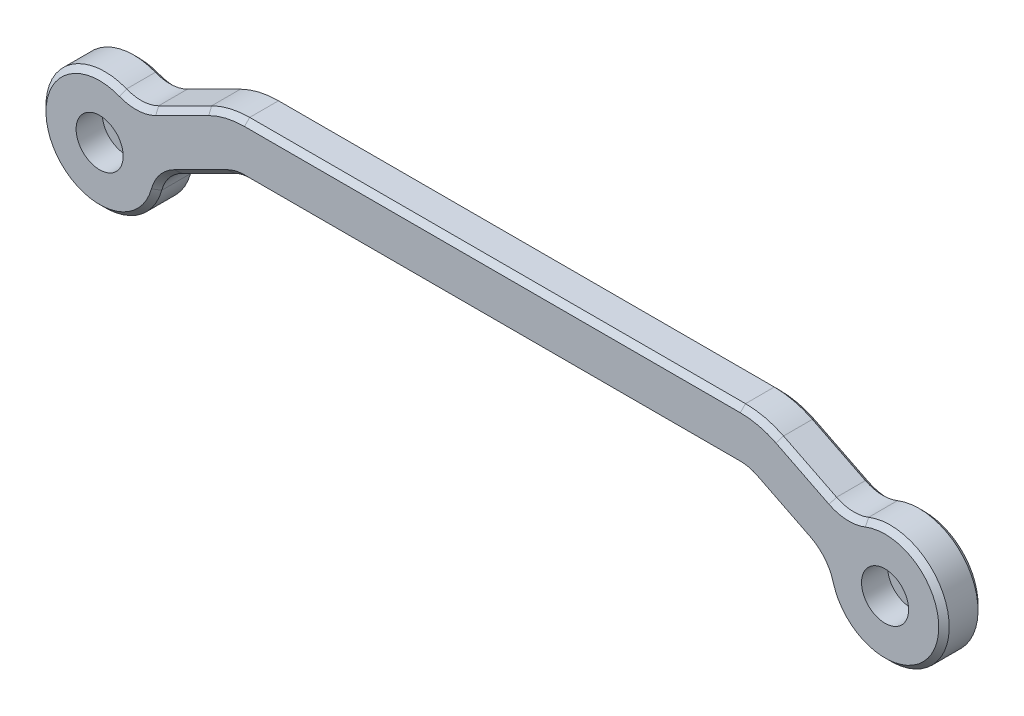
from build123d import *

# Parameters (mm, degrees)
SKETCH1_R           = 2.05
BOSS_EXTRUDE1_DEPTH = 6
SKETCH3_R           = 3.6
CUT_EXTRUDE1_DEPTH  = 4
CHAMFER3_SIZE       = 0.8


with BuildPart() as part:
    # Sketch1 → Boss-Extrude1 (new body)
    with BuildSketch(Plane.XY):
        with BuildLine():
            Line((-51.788854382, 8.577708764), (-43.689164944, 12.627553483))
            ThreePointArc((-43.689164944, 12.627553483), (-40.86217617, 13.652236863), (-37.875388203, 14))
            Line((-37.875388203, 14), (37.875388203, 14))
            ThreePointArc((37.875388203, 14), (40.86217617, 13.652236863), (43.689164944, 12.627553483))
            Line((43.689164944, 12.627553483), (51.788854382, 8.577708764))
            ThreePointArc((51.788854382, 8.577708764), (54.213536442, 7.949847309), (56.683281573, 8.366563146))
            ThreePointArc((56.683281573, 8.366563146), (68.049844719, -4.024922359), (51.316718427, -2.366563146))
            ThreePointArc((51.316718427, -2.366563146), (50.168244018, -0.140737539), (48.211145618, 1.422291236))
            Line((48.211145618, 1.422291236), (40.11145618, 5.472135955))
            ThreePointArc((40.11145618, 5.472135955), (39.024152805, 5.866244947), (37.875388203, 6))
            Line((37.875388203, 6), (-37.875388203, 6))
            ThreePointArc((-37.875388203, 6), (-39.024152805, 5.866244947), (-40.11145618, 5.472135955))
            Line((-40.11145618, 5.472135955), (-48.211145618, 1.422291236))
            ThreePointArc((-48.211145618, 1.422291236), (-50.168244018, -0.140737539), (-51.316718427, -2.366563146))
            ThreePointArc((-51.316718427, -2.366563146), (-68.049844719, -4.024922359), (-56.683281573, 8.366563146))
            ThreePointArc((-56.683281573, 8.366563146), (-54.213536442, 7.949847309), (-51.788854382, 8.577708764))
        make_face()
        with Locations((-60, 0)):
            Circle(SKETCH1_R, mode=Mode.SUBTRACT)
        with Locations((60, 0)):
            Circle(SKETCH1_R, mode=Mode.SUBTRACT)
    extrude(amount=BOSS_EXTRUDE1_DEPTH)

    # Sketch3 → Cut-Extrude1 (cut)
    with BuildSketch(Plane.XY.offset(6)):
        with Locations((-60, 0)):
            Circle(SKETCH3_R)
        with Locations((60, 0)):
            Circle(SKETCH3_R)
    extrude(amount=-CUT_EXTRUDE1_DEPTH, mode=Mode.SUBTRACT)

    # Chamfer3
    chamfer3_edges = [part.edges().sort_by_distance(p)[0] for p in [
        (-40.86217617, 13.652236863, 6),
        (47.739009663, 10.602631123, 0),
        (54.213536442, 7.949847309, 0),
        (68.049844719, -4.024922359, 0),
        (-47.739009663, 10.602631123, 6),
        (50.168244018, -0.140737539, 0),
        (44.161300899, 3.447213595, 0),
        (39.024152805, 5.866244947, 0),
        (0, 6, 0),
        (-39.024152805, 5.866244947, 0),
        (-44.161300899, 3.447213595, 0),
        (-50.168244018, -0.140737539, 0),
        (-68.049844719, -4.024922359, 0),
        (-54.213536442, 7.949847309, 0),
        (-47.739009663, 10.602631123, 0),
        (-54.213536442, 7.949847309, 6),
        (-40.86217617, 13.652236863, 0),
        (0, 14, 0),
        (40.86217617, 13.652236863, 0),
        (-68.049844719, -4.024922359, 6),
        (-50.168244018, -0.140737539, 6),
        (-44.161300899, 3.447213595, 6),
        (-39.024152805, 5.866244947, 6),
        (0, 6, 6),
        (39.024152805, 5.866244947, 6),
        (44.161300899, 3.447213595, 6),
        (40.86217617, 13.652236863, 6),
        (50.168244018, -0.140737539, 6),
        (68.049844719, -4.024922359, 6),
        (54.213536442, 7.949847309, 6),
        (47.739009663, 10.602631123, 6),
        (0, 14, 6),
    ]]
    chamfer(chamfer3_edges, length=CHAMFER3_SIZE)


solid = part.part
